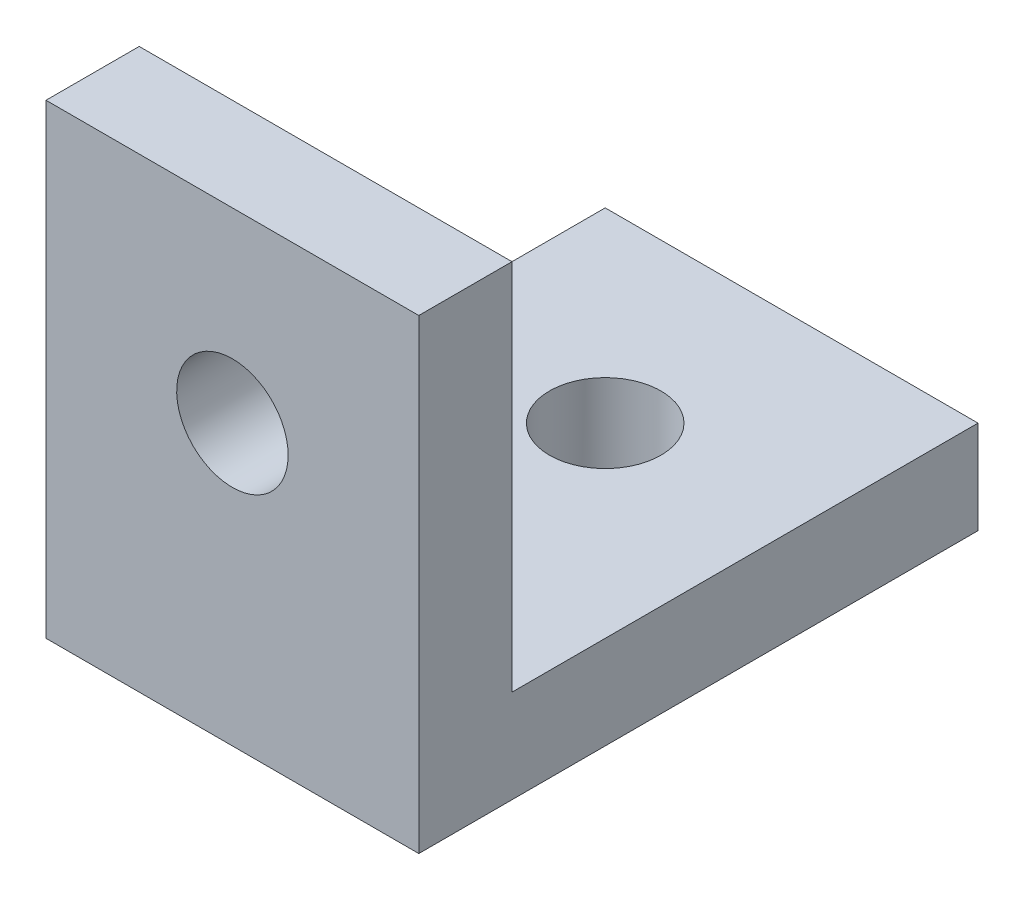
from build123d import *

# Parameters (mm, degrees)
EXTRUDE1_DEPTH                      = 6.35
EXTRUDE1_DEPTH_BACK                 = 6.35
F_6_CLEARANCE_HOLE1_D               = 3.7973
F_6_CLEARANCE_HOLE1_DEPTH           = 12.7
F_6_CLEARANCE_HOLE1_TIP             = 1.140824014
F_6_CLEARANCE_HOLE1_ON_FACE_2_D     = 3.7973
F_6_CLEARANCE_HOLE1_ON_FACE_2_DEPTH = 12.7
F_6_CLEARANCE_HOLE1_ON_FACE_2_TIP   = 1.140824014


with BuildPart() as part:
    # Sketch2 → Extrude1 (new, two sides: drawn at the far end of the back side and taken through both)
    with BuildSketch(Plane(origin=(0, 0, 0), x_dir=(0, 0, -1), z_dir=(1, 0, 0)).offset(-EXTRUDE1_DEPTH_BACK)):
        Polygon((0, 0), (0, 15.875), (3.175, 15.875), (3.175, 3.175), (19.05, 3.175), (19.05, 0), align=None)
    extrude(amount=EXTRUDE1_DEPTH + EXTRUDE1_DEPTH_BACK)

    # 6 Clearance Hole1
    with Locations(Plane(origin=(0, 9.525, -3.175), x_dir=(0, -1, 0), z_dir=(0, 0, -1))):
        with Locations((0, 0)):
            Hole(F_6_CLEARANCE_HOLE1_D / 2, depth=F_6_CLEARANCE_HOLE1_DEPTH)
            with Locations((0, 0, -(F_6_CLEARANCE_HOLE1_DEPTH + F_6_CLEARANCE_HOLE1_TIP / 2))):  # 118° drill point
                Cone(0, F_6_CLEARANCE_HOLE1_D / 2, F_6_CLEARANCE_HOLE1_TIP, mode=Mode.SUBTRACT)

    # 6 Clearance Hole1 on face 2
    with Locations(Plane(origin=(0, 3.175, -12.7), x_dir=(0, 0, 1), z_dir=(0, 1, 0))):
        with Locations((0, 0)):
            Hole(F_6_CLEARANCE_HOLE1_ON_FACE_2_D / 2, depth=F_6_CLEARANCE_HOLE1_ON_FACE_2_DEPTH)
            with Locations((0, 0, -(F_6_CLEARANCE_HOLE1_ON_FACE_2_DEPTH + F_6_CLEARANCE_HOLE1_ON_FACE_2_TIP / 2))):  # 118° drill point
                Cone(0, F_6_CLEARANCE_HOLE1_ON_FACE_2_D / 2, F_6_CLEARANCE_HOLE1_ON_FACE_2_TIP, mode=Mode.SUBTRACT)


solid = part.part
